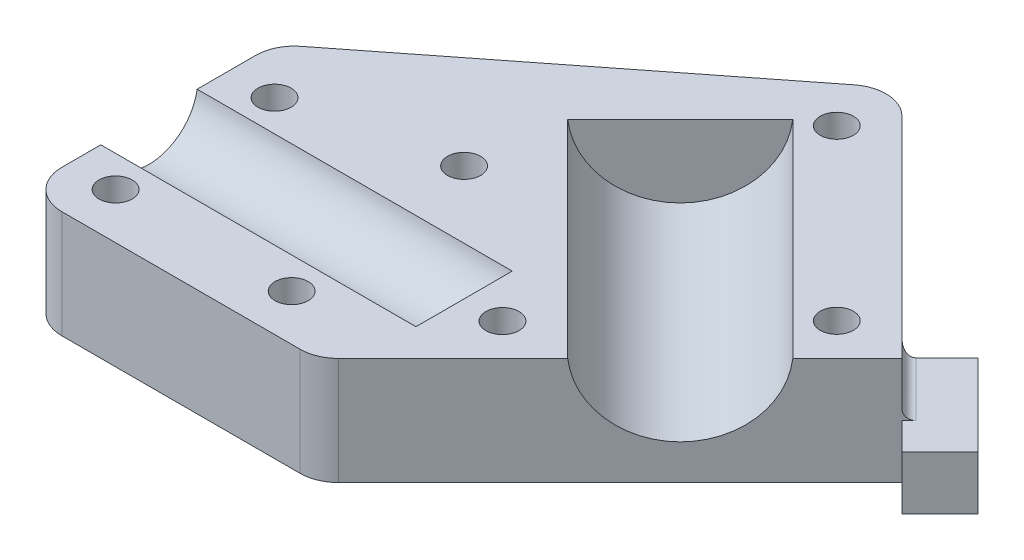
from build123d import *

# Parameters (mm, degrees)
EXTRUDE_1_DEPTH        = 14
EXTRUDE_2_DEPTH        = 7
CUT_EXTRUDE_1_DEPTH    = 41.028932
CUT_EXTRUDE_2_DEPTH    = 38.1
HOLE_WIZARD_M4_1_D     = 4.318
HOLE_WIZARD_M4_1_DEPTH = 14
FILLET_1_R             = 5
FILLET_3_R             = 1.27
FILLET_4_R             = 1.27


with BuildPart() as part:
    # 草图1 → 凸台-拉伸1 (new body)
    with BuildSketch(Plane.XZ.offset(15)):
        Polygon((4.743453, -52.27499), (35.219756, -21.798688), (-2.928932, 16.35), (-41.028932, 16.35), (-41.028932, -16.35), align=None)
    extrude(amount=-EXTRUDE_1_DEPTH)

    # 草图2 → 凸台-拉伸2 (add)
    with BuildSketch(Plane.XZ.offset(15)):
        Polygon((43.705037, -23.212901), (38.75529, -18.263154), (35.219756, -21.798688), (28.148688, -28.869756), (33.098435, -33.819503), align=None)
    extrude(amount=-EXTRUDE_2_DEPTH)

    # 草图3 → 切除-拉伸1 (cut)
    with BuildSketch(Plane.ZY.offset(41.028932)):
        with BuildLine():
            Line((6.270766, -1), (-6.270766, -1))
            ThreePointArc((-6.270766, -1), (0, -6.35), (6.270766, -1))
        make_face()
    extrude(amount=-CUT_EXTRUDE_1_DEPTH, mode=Mode.SUBTRACT)

    # 草图4 → 切除-拉伸2 (cut)
    with BuildSketch(Plane(origin=(6.710534, 0, 6.710534), x_dir=(0.707107, 0, -0.707107), z_dir=(0.707107, 0, 0.707107))):
        with BuildLine():
            Line((30.270005, -1), (9.538252, -1))
            ThreePointArc((9.538252, -1), (19.904128, -10.414), (30.270005, -1))
        make_face()
    extrude(amount=-CUT_EXTRUDE_2_DEPTH, mode=Mode.SUBTRACT)

    # M4 间隙孔1
    with Locations(Plane(origin=(0, -15, 0), x_dir=(-1, 0, 0), z_dir=(0, -1, 0))):
        with Locations((35.028932, -10.35), (-5, 0), (15, 15), (12.103043, -10.35), (35.028932, 10.35), (-4.743453, 43.789709), (-26.734474, 21.798688)):
            Hole(HOLE_WIZARD_M4_1_D / 2, depth=HOLE_WIZARD_M4_1_DEPTH)

    # 圆角1
    fillet_1_edges = [part.edges().sort_by_distance(p)[0] for p in [
        (-41.028932, -8, -16.35),
        (-41.028932, -8, 16.35),
        (-2.928932, -8, 16.35),
        (4.743453, -8, -52.27499),
    ]]
    fillet(fillet_1_edges, radius=FILLET_1_R)

    # 圆角3
    fillet_3_edges = [part.edges().sort_by_distance(p)[0] for p in [
        (31.684222, -8, -25.334222),
    ]]
    fillet(fillet_3_edges, radius=FILLET_3_R)

    # 圆角4
    fillet_4_edges = [part.edges().sort_by_distance(p)[0] for p in [
        (28.148688, -11.5, -28.869756),
    ]]
    fillet(fillet_4_edges, radius=FILLET_4_R)


solid = part.part
